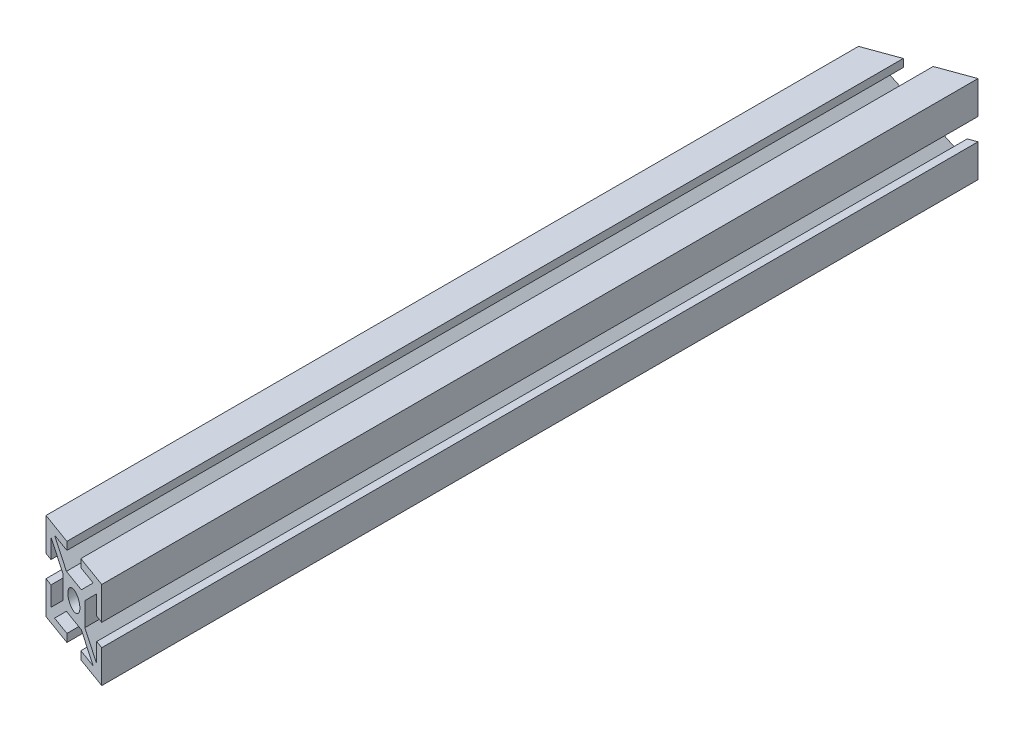
from build123d import *

# Parameters (mm, degrees)
SKETCH2_R           = 2.15
BOSS_EXTRUDE1_DEPTH = 100
CUT_EXTRUDE1_DEPTH  = 21
CUT_EXTRUDE2_DEPTH  = 21


with BuildPart() as part:
    # Sketch2 → Boss-Extrude1 (new body, symmetric)
    with BuildSketch(Plane.XY):
        Polygon((-2.5, 10), (-2.5, 8.2), (-6.927207794, 8.2), (-2.677207794, 3.95), (2.677207794, 3.95), (6.927207794, 8.2), (2.5, 8.2), (2.5, 10), (10, 10), (10, 2.5), (8.2, 2.5), (8.2, 6.927207794), (3.95, 2.677207794), (3.95, -2.677207794), (8.2, -6.927207794), (8.2, -2.5), (10, -2.5), (10, -10), (2.5, -10), (2.5, -8.2), (6.927207794, -8.2), (2.677207794, -3.95), (-2.677207794, -3.95), (-6.927207794, -8.2), (-2.5, -8.2), (-2.5, -10), (-10, -10), (-10, -2.5), (-8.2, -2.5), (-8.2, -6.927207794), (-3.95, -2.677207794), (-3.95, 2.677207794), (-8.2, 6.927207794), (-8.2, 2.5), (-10, 2.5), (-10, 10), align=None)
        Circle(SKETCH2_R, mode=Mode.SUBTRACT)
    extrude(amount=BOSS_EXTRUDE1_DEPTH, both=True)

    # Sketch3 → Cut-Extrude1 (cut, through all)
    with BuildSketch(Plane(origin=(0, 10, 0), x_dir=(1, 0, 0), z_dir=(0, 1, 0))):
        Polygon((-10, -100), (10, -100), (-10, -92.720595315), align=None)
    extrude(amount=-CUT_EXTRUDE1_DEPTH, mode=Mode.SUBTRACT)

    # Sketch4 → Cut-Extrude2 (cut, through all)
    with BuildSketch(Plane(origin=(0, 10, 0), x_dir=(1, 0, 0), z_dir=(0, 1, 0))):
        Polygon((10, 100), (-10, 100), (-10, 92.720595315), align=None)
    extrude(amount=-CUT_EXTRUDE2_DEPTH, mode=Mode.SUBTRACT)


solid = part.part
